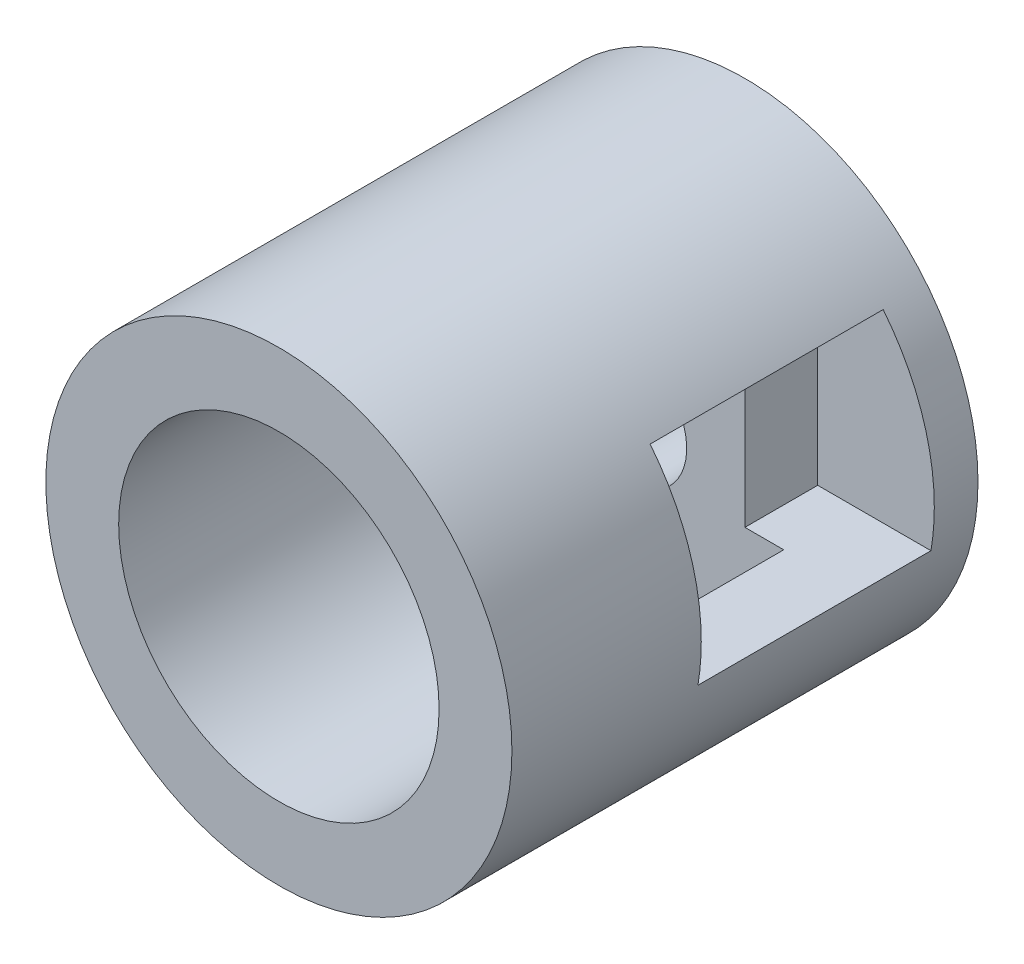
from build123d import *

# Parameters (mm, degrees)
SKETCH1_R               = 4
BOSS_EXTRUDE1_DEPTH     = 6
SKETCH2_R               = 2.75
CUT_EXTRUDE1_DEPTH      = 6
SKETCH3_R               = 4
BOSS_EXTRUDE2_DEPTH     = 2
SKETCH4_R               = 1
CUT_EXTRUDE2_DEPTH      = 2
CUT_EXTRUDE8_DEPTH      = 2
CUT_EXTRUDE8_DEPTH_BACK = 2
SKETCH9_W               = 4
SKETCH9_H               = 3.175


with BuildPart() as part:
    # Sketch1 → Boss-Extrude1 (new body)
    with BuildSketch(Plane.XY):
        Circle(SKETCH1_R)
    extrude(amount=-BOSS_EXTRUDE1_DEPTH)

    # Sketch2 → Cut-Extrude1 (cut)
    with BuildSketch(Plane(origin=(0, 0, -6), x_dir=(-1, 0, 0), z_dir=(0, 0, -1))):
        Circle(SKETCH2_R)
    extrude(amount=-CUT_EXTRUDE1_DEPTH, mode=Mode.SUBTRACT)

    # Sketch3 → Boss-Extrude2 (add)
    with BuildSketch(Plane(origin=(0, 0, -6), x_dir=(-1, 0, 0), z_dir=(0, 0, -1))):
        Circle(SKETCH3_R)
    extrude(amount=BOSS_EXTRUDE2_DEPTH)

    # Sketch4 → Cut-Extrude2 (cut)
    with BuildSketch(Plane(origin=(0, 0, -8), x_dir=(-1, 0, 0), z_dir=(0, 0, -1))):
        Circle(SKETCH4_R)
    extrude(amount=-CUT_EXTRUDE2_DEPTH, mode=Mode.SUBTRACT)

    # Sketch9 → Cut-Extrude8 (cut, two sides: drawn at the far end of the back side and taken through both)
    with BuildSketch(Plane(origin=(3.998726485, 0, 0), x_dir=(0, 0, -1), z_dir=(1, 0, 0)).offset(-CUT_EXTRUDE8_DEPTH_BACK)):
        with Locations((5.25, 0.9125)):
            Rectangle(SKETCH9_W, SKETCH9_H)
    extrude(amount=CUT_EXTRUDE8_DEPTH + CUT_EXTRUDE8_DEPTH_BACK, mode=Mode.SUBTRACT)


solid = part.part
